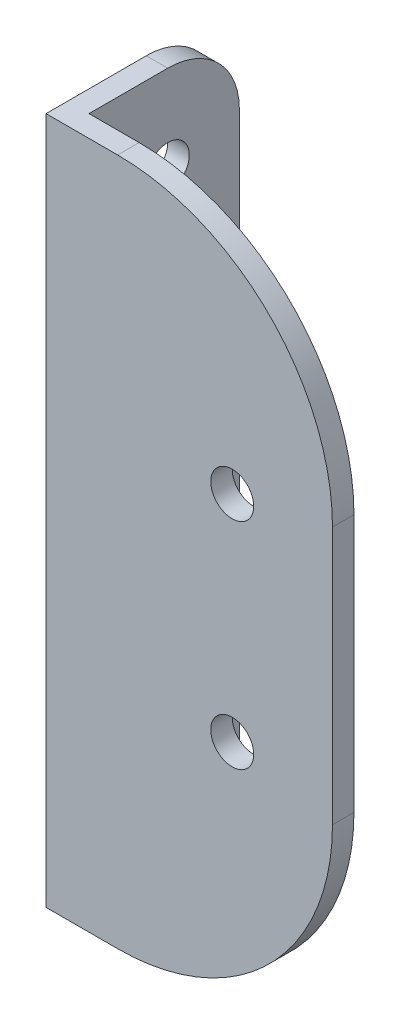
from build123d import *

# Parameters (mm, degrees)
BOSS_EXTRUDE1_DEPTH = 48
SKETCH2_R           = 1.5
CUT_EXTRUDE1_DEPTH  = 13
SKETCH3_R           = 1.5
SKETCH3_R_2         = 3
CUT_EXTRUDE3_DEPTH  = 21
FILLET1_R           = 5
FILLET2_R           = 15


with BuildPart() as part:
    # Sketch1 → Boss-Extrude1 (new body)
    with BuildSketch(Plane(origin=(0, 0, 0), x_dir=(1, 0, 0), z_dir=(0, 1, 0))):
        Polygon((0, 0), (0, 12), (1.5, 12), (1.5, 1.5), (20, 1.5), (20, 0), align=None)
    extrude(amount=BOSS_EXTRUDE1_DEPTH)

    # Sketch2 → Cut-Extrude1 (cut, through all)
    with BuildSketch(Plane.XY):
        with Locations((13, 31.5)):
            Circle(SKETCH2_R)
        with Locations((13, 16.5)):
            Circle(SKETCH2_R)
    extrude(amount=-CUT_EXTRUDE1_DEPTH, mode=Mode.SUBTRACT)

    # Sketch3 → Cut-Extrude3 (cut, through all)
    with BuildSketch(Plane(origin=(0, 0, 0), x_dir=(0, 0, -1), z_dir=(1, 0, 0))):
        with Locations((7, 42)):
            Circle(SKETCH3_R)
        with Locations((7, 24)):
            Circle(SKETCH3_R_2)
        with Locations((7, 6)):
            Circle(SKETCH3_R)
    extrude(amount=CUT_EXTRUDE3_DEPTH, mode=Mode.SUBTRACT)

    # Fillet1
    fillet1_edges = [part.edges().sort_by_distance(p)[0] for p in [
        (0.75, 48, -12),
        (0.75, 0, -12),
    ]]
    fillet(fillet1_edges, radius=FILLET1_R)

    # Fillet2
    fillet2_edges = [part.edges().sort_by_distance(p)[0] for p in [
        (20, 48, -0.75),
        (20, 0, -0.75),
    ]]
    fillet(fillet2_edges, radius=FILLET2_R)


solid = part.part
